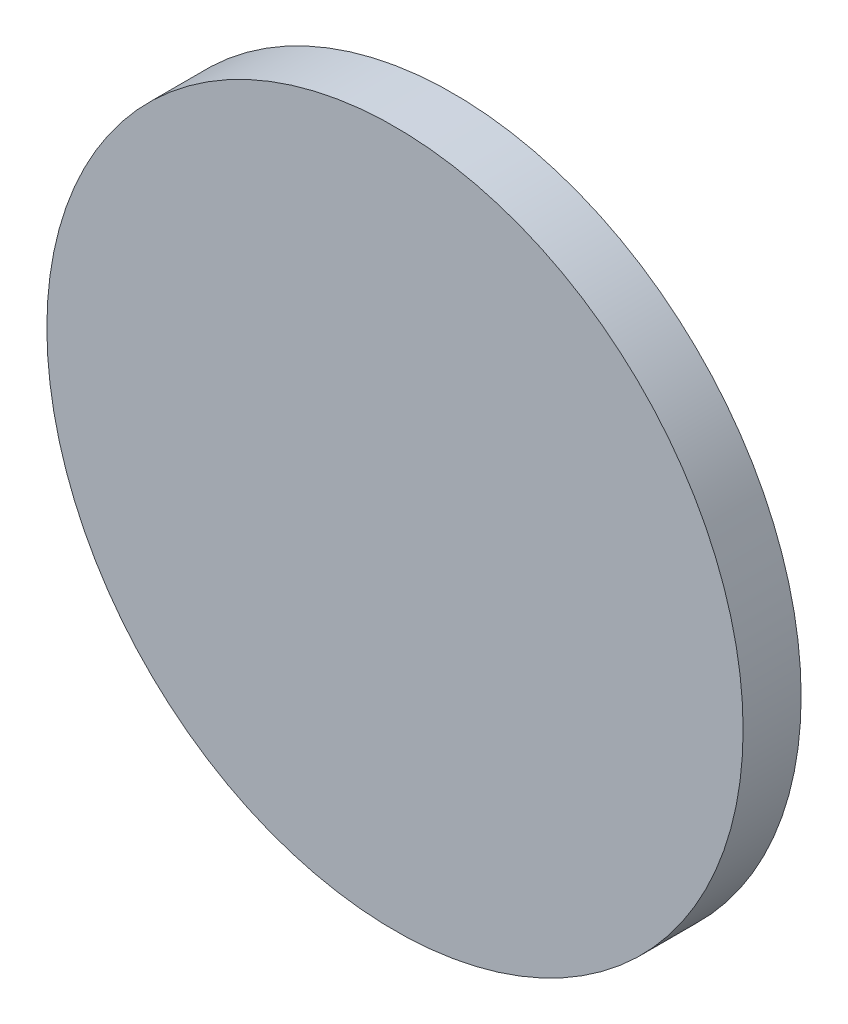
from build123d import *

# Parameters (mm, degrees)
SKETCH1_R           = 6
BOSS_EXTRUDE1_DEPTH = 1


with BuildPart() as part:
    # Sketch1 → Boss-Extrude1 (new body)
    with BuildSketch(Plane.XY):
        Circle(SKETCH1_R)
    extrude(amount=BOSS_EXTRUDE1_DEPTH)


solid = part.part
